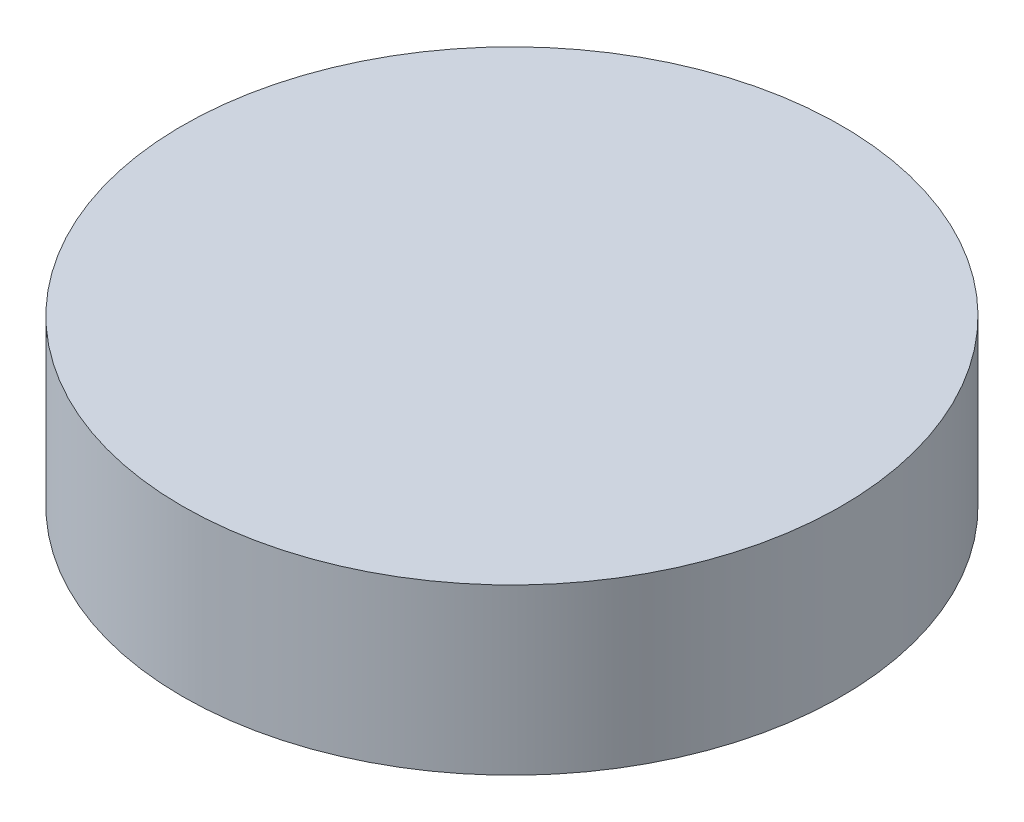
from build123d import *

# Parameters (mm, degrees)
SKETCH1_R           = 3
BOSS_EXTRUDE1_DEPTH = 1.5


with BuildPart() as part:
    # Sketch1 → Boss-Extrude1 (new body)
    with BuildSketch(Plane(origin=(0, 0, 0), x_dir=(1, 0, 0), z_dir=(0, 1, 0))):
        Circle(SKETCH1_R)
    extrude(amount=BOSS_EXTRUDE1_DEPTH)


solid = part.part
